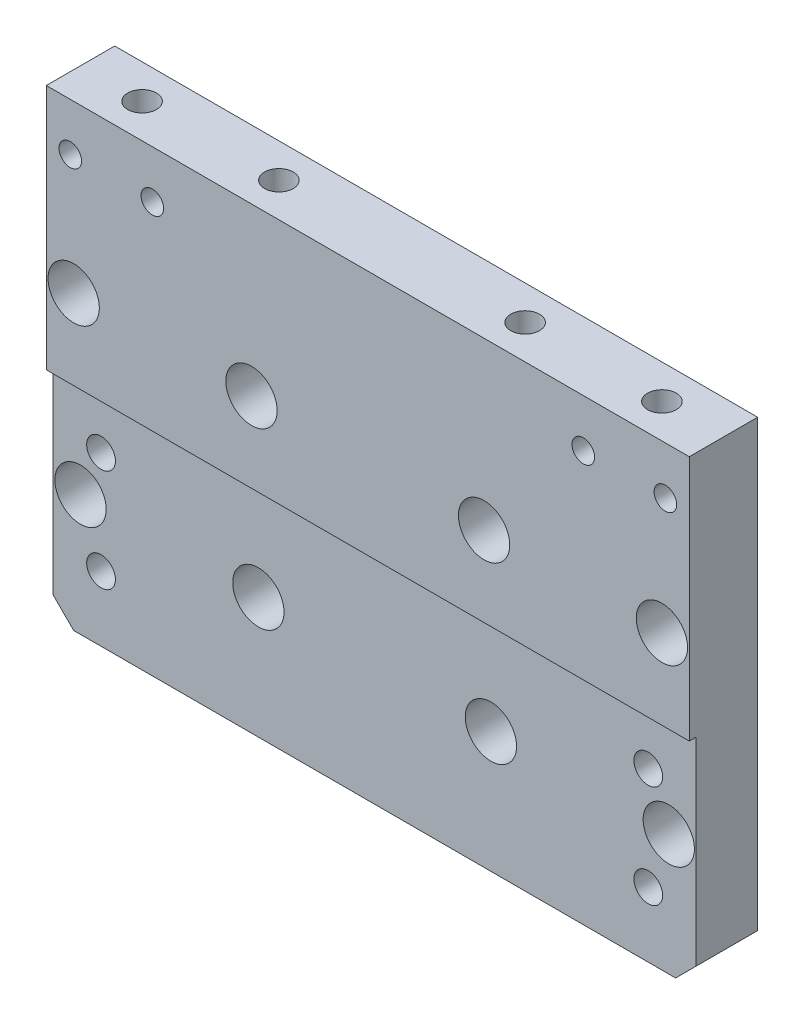
from build123d import *

# Parameters (mm, degrees)
SKETCH1_W                                           = 94
SKETCH1_H                                           = 68
BOSS_EXTRUDE1_DEPTH                                 = 10
M5_TAPPED_HOLE1_D                                   = 4.2
M5_TAPPED_HOLE1_DEPTH                               = 14
M5_TAPPED_HOLE1_TIP                                 = 1.2618073
SKETCH4_W                                           = 94
SKETCH4_H                                           = 32
CUT_EXTRUDE1_DEPTH                                  = 1
CHAMFER1_SIZE                                       = 3
CBORE_FOR_M4_HEX_SOCKET_HEAD_CAP_SCREW5_D           = 4.5
CBORE_FOR_M4_HEX_SOCKET_HEAD_CAP_SCREW5_CBORE_D     = 7.5
CBORE_FOR_M4_HEX_SOCKET_HEAD_CAP_SCREW5_CBORE_DEPTH = 5.8
M5_TAPPED_HOLE2_D                                   = 4.2
M5_TAPPED_HOLE2_DEPTH                               = 14
M5_TAPPED_HOLE2_TIP                                 = 1.2618073
M4_TAPPED_HOLE1_D                                   = 3.3
M4_TAPPED_HOLE1_DEPTH                               = 11.5
M4_TAPPED_HOLE1_TIP                                 = 0.991420021
CBORE_FOR_M4_HEX_SOCKET_HEAD_CAP_SCREW6_D           = 4.5
CBORE_FOR_M4_HEX_SOCKET_HEAD_CAP_SCREW6_CBORE_D     = 7.5
CBORE_FOR_M4_HEX_SOCKET_HEAD_CAP_SCREW6_CBORE_DEPTH = 5.8


with BuildPart() as part:
    # Sketch1 → Boss-Extrude1 (new body)
    with BuildSketch(Plane.XY):
        with Locations((47, 34)):
            Rectangle(SKETCH1_W, SKETCH1_H)
    extrude(amount=BOSS_EXTRUDE1_DEPTH)

    # M5 Tapped Hole1
    with Locations(Plane(origin=(9, 68, 5), x_dir=(1, 0, 0), z_dir=(0, 1, 0))):
        with Locations((0, 0), (20, 0), (56, 0), (76, 0)):
            Hole(M5_TAPPED_HOLE1_D / 2, depth=M5_TAPPED_HOLE1_DEPTH)
            with Locations((0, 0, -(M5_TAPPED_HOLE1_DEPTH + M5_TAPPED_HOLE1_TIP / 2))):  # 118° drill point
                Cone(0, M5_TAPPED_HOLE1_D / 2, M5_TAPPED_HOLE1_TIP, mode=Mode.SUBTRACT)

    # Sketch4 → Cut-Extrude1 (cut)
    with BuildSketch(Plane.XY.offset(10)):
        with Locations((47, 16)):
            Rectangle(SKETCH4_W, SKETCH4_H)
    extrude(amount=-CUT_EXTRUDE1_DEPTH, mode=Mode.SUBTRACT)

    # Chamfer1
    chamfer1_edges = [part.edges().sort_by_distance(p)[0] for p in [
        (0, 0, 4.5),
        (94, 0, 4.5),
    ]]
    chamfer(chamfer1_edges, length=CHAMFER1_SIZE)

    # CBORE for M4 Hex Socket Head Cap Screw5 (through all)
    with Locations(Plane(origin=(4, 17.7, 9), x_dir=(1, 0, 0), z_dir=(0, 0, 1))):
        with Locations((0, 0), (26, 0), (60, 0), (86, 0)):
            CounterBoreHole(CBORE_FOR_M4_HEX_SOCKET_HEAD_CAP_SCREW5_D / 2, CBORE_FOR_M4_HEX_SOCKET_HEAD_CAP_SCREW5_CBORE_D / 2, CBORE_FOR_M4_HEX_SOCKET_HEAD_CAP_SCREW5_CBORE_DEPTH)

    # M5 Tapped Hole2
    with Locations(Plane(origin=(7, 24.5, 9), x_dir=(1, 0, 0), z_dir=(0, 0, 1))):
        with Locations((0, 0), (0, -15), (80, 0), (80, -15)):
            Hole(M5_TAPPED_HOLE2_D / 2, depth=M5_TAPPED_HOLE2_DEPTH)
            with Locations((0, 0, -(M5_TAPPED_HOLE2_DEPTH + M5_TAPPED_HOLE2_TIP / 2))):  # 118° drill point
                Cone(0, M5_TAPPED_HOLE2_D / 2, M5_TAPPED_HOLE2_TIP, mode=Mode.SUBTRACT)

    # M4 Tapped Hole1
    with Locations(Plane(origin=(3.5, 61, 10), x_dir=(1, 0, 0), z_dir=(0, 0, 1))):
        with Locations((0, 0), (12, 0), (75, 0), (87, 0)):
            Hole(M4_TAPPED_HOLE1_D / 2, depth=M4_TAPPED_HOLE1_DEPTH)
            with Locations((0, 0, -(M4_TAPPED_HOLE1_DEPTH + M4_TAPPED_HOLE1_TIP / 2))):  # 118° drill point
                Cone(0, M4_TAPPED_HOLE1_D / 2, M4_TAPPED_HOLE1_TIP, mode=Mode.SUBTRACT)

    # CBORE for M4 Hex Socket Head Cap Screw6 (through all)
    with Locations(Plane(origin=(4, 43.7, 10), x_dir=(1, 0, 0), z_dir=(0, 0, 1))):
        with Locations((0, 0), (26, 0), (60, 0), (86, 0)):
            CounterBoreHole(CBORE_FOR_M4_HEX_SOCKET_HEAD_CAP_SCREW6_D / 2, CBORE_FOR_M4_HEX_SOCKET_HEAD_CAP_SCREW6_CBORE_D / 2, CBORE_FOR_M4_HEX_SOCKET_HEAD_CAP_SCREW6_CBORE_DEPTH)


solid = part.part
